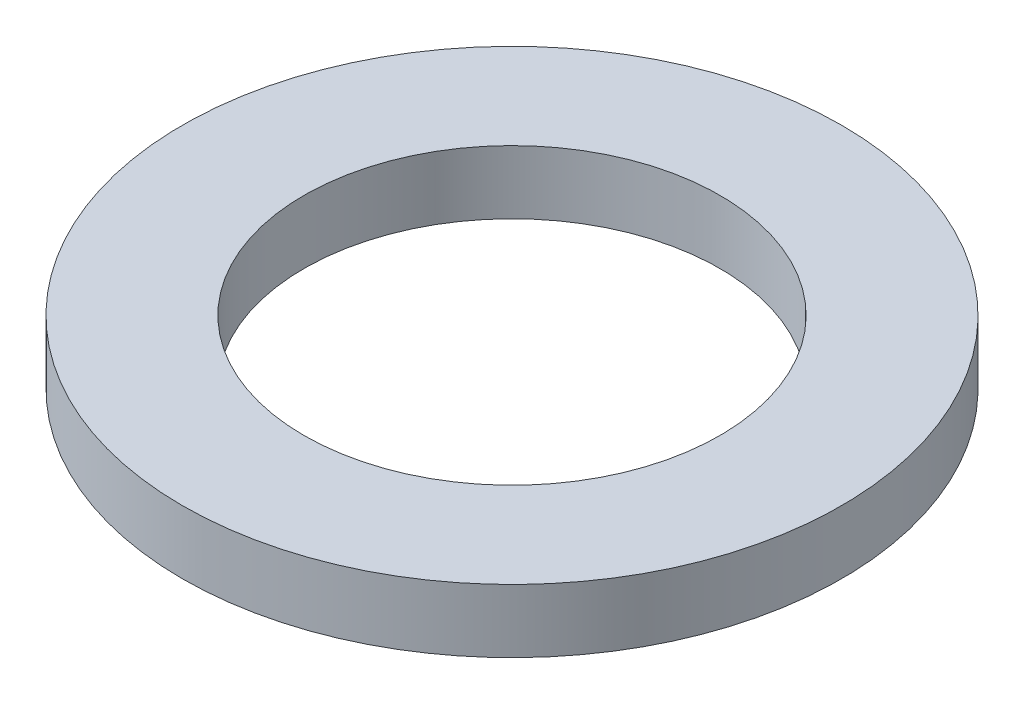
from build123d import *

# Parameters (mm, degrees)
SKETCH1_R           = 66.04
SKETCH1_R_2         = 41.6814
BOSS_EXTRUDE1_DEPTH = 12.7


with BuildPart() as part:
    # Sketch1 → Boss-Extrude1 (new body)
    with BuildSketch(Plane(origin=(0, 0, 0), x_dir=(1, 0, 0), z_dir=(0, 1, 0))):
        Circle(SKETCH1_R)
        Circle(SKETCH1_R_2, mode=Mode.SUBTRACT)
    extrude(amount=BOSS_EXTRUDE1_DEPTH)


solid = part.part
